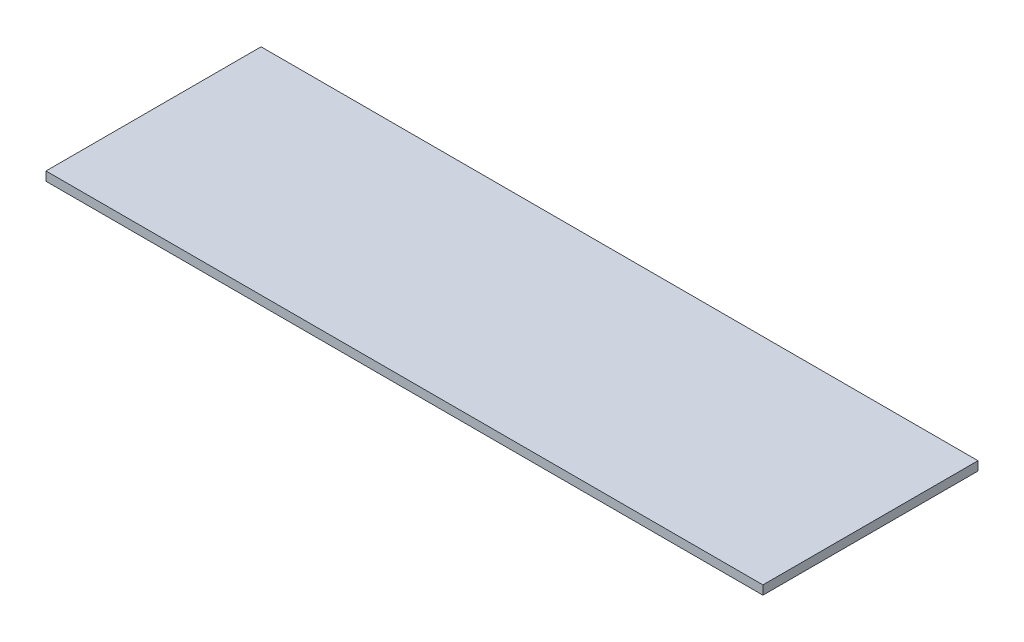
from build123d import *

# Parameters (mm, degrees)
SKETCH1_W           = 508
SKETCH1_H           = 152.4
BOSS_EXTRUDE1_DEPTH = 6.35


with BuildPart() as part:
    # Sketch1 → Boss-Extrude1 (new body)
    with BuildSketch(Plane(origin=(0, 0, 0), x_dir=(1, 0, 0), z_dir=(0, 1, 0))):
        with Locations((254, 76.2)):
            Rectangle(SKETCH1_W, SKETCH1_H)
    extrude(amount=BOSS_EXTRUDE1_DEPTH)


solid = part.part
